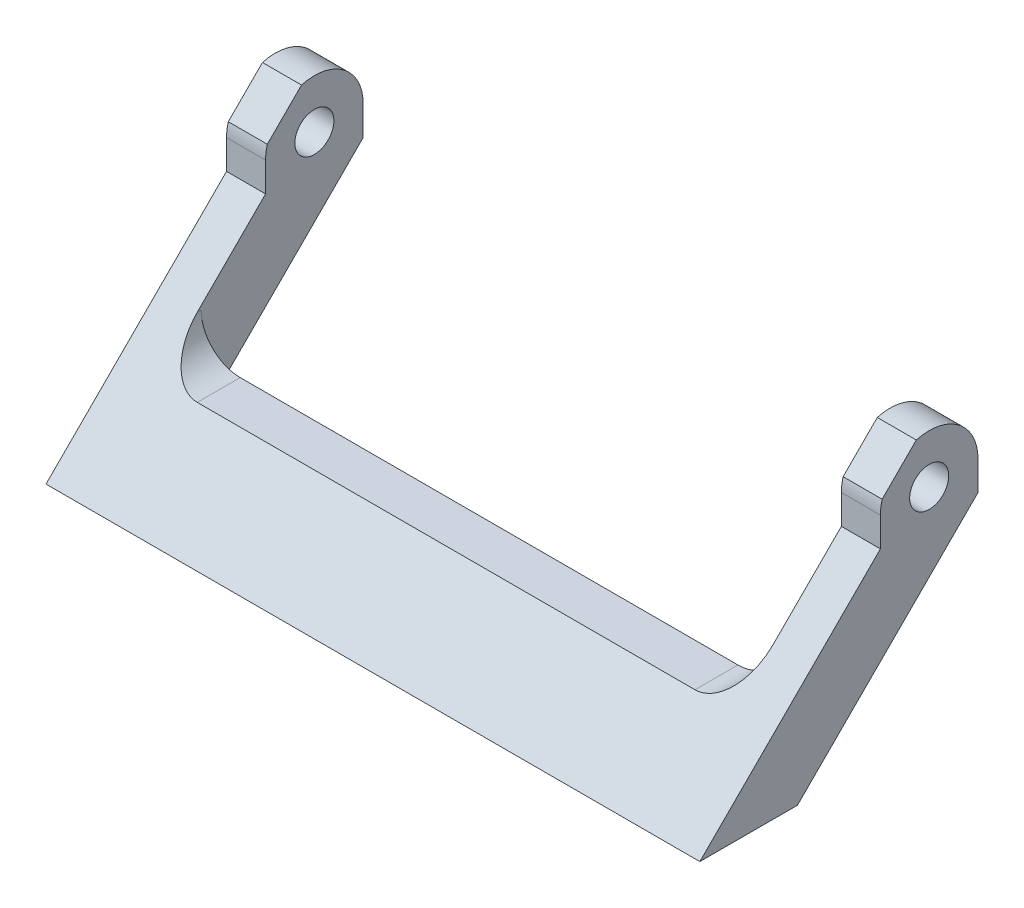
from build123d import *

# Parameters (mm, degrees)
SKETCH1_R           = 2
BOSS_EXTRUDE1_DEPTH = 67
CUT_EXTRUDE1_REACH  = 30.5
CUT_EXTRUDE2_REACH  = 28.5
SKETCH3_W           = 59
SKETCH3_H           = 9.6
SKETCH4_OUTSIDE_W   = 45.996
SKETCH4_OUTSIDE_H   = 43.996
CUT_EXTRUDE3_DEPTH  = 68


with BuildPart() as part:
    # Sketch1 → Boss-Extrude1 (new body)
    with BuildSketch(Plane(origin=(0, 0, 0), x_dir=(0, 0, -1), z_dir=(1, 0, 0))):
        with BuildLine():
            Line((11.9, 1.9), (11.9, 0))
            Line((11.9, 0), (0, 0))
            Line((0, 0), (18.5, 18.5))
            Line((18.5, 18.5), (18.5, 21.5))
            ThreePointArc((18.5, 21.5), (23.5, 26.5), (28.5, 21.5))
            Line((28.5, 21.5), (28.5, 18.5))
            Line((28.5, 18.5), (11.9, 1.9))
        make_face()
        with Locations((23.5, 21.5)):
            Circle(SKETCH1_R, mode=Mode.SUBTRACT)
    extrude(amount=BOSS_EXTRUDE1_DEPTH)

    # Sketch2 → Cut-Extrude1 (cut, up to next)
    with BuildSketch(Plane(origin=(0, 0, -28.5), x_dir=(-1, 0, 0), z_dir=(0, 0, -1)), mode=Mode.PRIVATE) as cut_extrude1_sk1:
        with BuildLine():
            Line((-63, 26.5), (-63, 11.5))
            ThreePointArc((-63, 11.5), (-61.828427125, 8.671572875), (-59, 7.5))
            Line((-59, 7.5), (-8, 7.5))
            ThreePointArc((-8, 7.5), (-5.171572875, 8.671572875), (-4, 11.5))
            Line((-4, 11.5), (-4, 26.5))
            Line((-4, 26.5), (-63, 26.5))
        make_face()
    cut_extrude1_tool1 = extrude(cut_extrude1_sk1.sketch, amount=-CUT_EXTRUDE1_REACH, mode=Mode.PRIVATE) & part.part
    add(cut_extrude1_tool1.solids().sort_by_distance((33.5, 17.053049, -28.5))[0], mode=Mode.SUBTRACT)

    # Sketch3 → Cut-Extrude2 (cut, up to next)
    with BuildSketch(Plane.XZ, mode=Mode.PRIVATE) as cut_extrude2_sk1:
        with Locations((33.5, -16.7)):
            Rectangle(SKETCH3_W, SKETCH3_H)
    cut_extrude2_tool1 = extrude(cut_extrude2_sk1.sketch, amount=-CUT_EXTRUDE2_REACH, mode=Mode.PRIVATE) & part.part
    add(cut_extrude2_tool1.solids().sort_by_distance((33.5, 0, -16.7))[0], mode=Mode.SUBTRACT)

    # Sketch4 outside → Cut-Extrude3 (cut, through all)
    with BuildSketch(Plane(origin=(67, 0, 0), x_dir=(0, 0, -1), z_dir=(1, 0, 0))):
        with Locations((14.25, 13.25)):
            Rectangle(SKETCH4_OUTSIDE_W, SKETCH4_OUTSIDE_H)
        Polygon((26.396638245, 30.538773869), (-4.319805153, -0.17766953), (2.751262658, -7.248737342), (33.467706057, 23.467706057), align=None, mode=Mode.SUBTRACT)
    extrude(amount=-CUT_EXTRUDE3_DEPTH, mode=Mode.SUBTRACT)


solid = part.part
